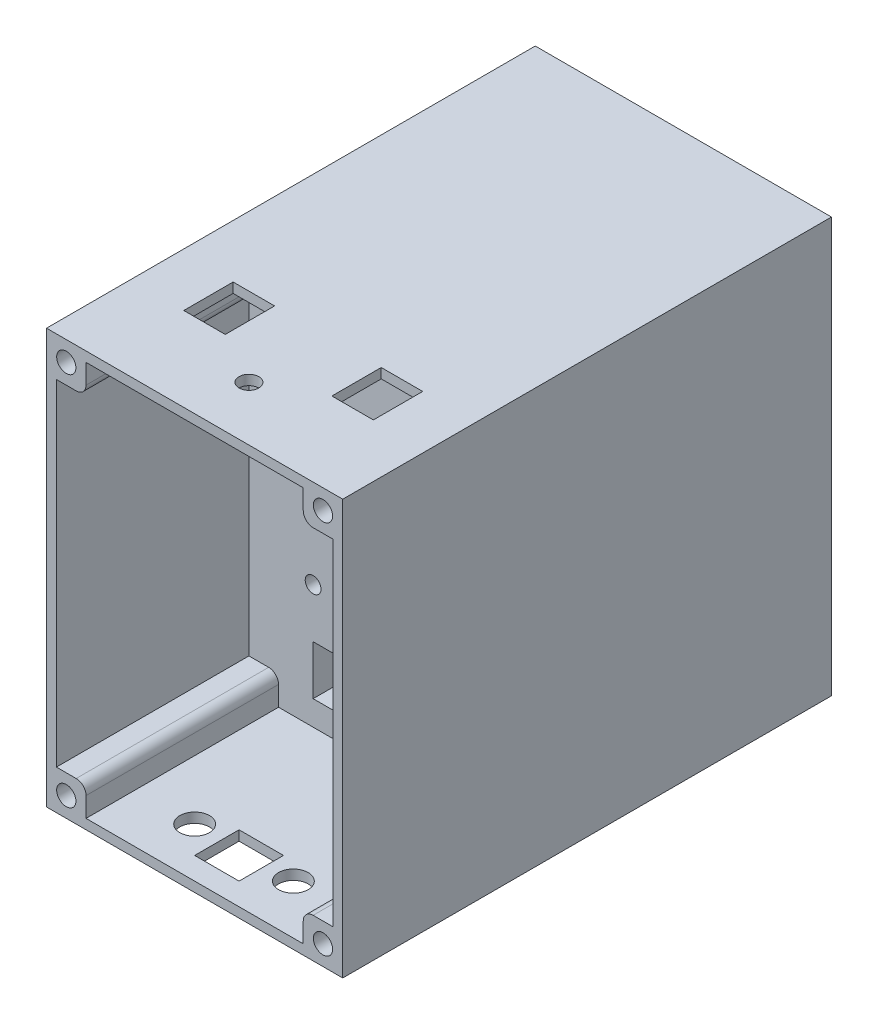
from build123d import *

# Parameters (mm, degrees)
SKETCH1_W                = 60
SKETCH1_H                = 84
BOSS_EXTRUDE2_DEPTH      = 82
BOSS_EXTRUDE2_DEPTH_BACK = 25
SKETCH2_W                = 56
SKETCH2_H                = 80
CUT_EXTRUDE1_DEPTH       = 108
BOSS_EXTRUDE6_DEPTH      = 107
SKETCH22_R               = 1.95
CUT_EXTRUDE6_DEPTH       = 25
CUT_EXTRUDE9_DEPTH       = 2
SKETCH28_W               = 8
SKETCH28_H               = 85.946450773
CUT_EXTRUDE11_DEPTH      = 60
BOSS_EXTRUDE9_DEPTH      = 84
SKETCH37_R               = 1.6
CUT_EXTRUDE15_DEPTH      = 4
CUT_EXTRUDE16_DEPTH      = 4
SKETCH41_R               = 2
CUT_EXTRUDE17_DEPTH      = 2
SKETCH42_R               = 11.5
CUT_EXTRUDE18_DEPTH      = 2.5
SKETCH43_R               = 5
CUT_EXTRUDE19_DEPTH      = 1.5
SKETCH44_R               = 3
CUT_EXTRUDE20_DEPTH      = 2


with BuildPart() as part:
    # Sketch1 → Boss-Extrude2 (new body, two sides)
    with BuildSketch(Plane.XY) as boss_extrude2_sk:
        with Locations((30, 42)):
            Rectangle(SKETCH1_W, SKETCH1_H)
    extrude(amount=BOSS_EXTRUDE2_DEPTH)
    extrude(boss_extrude2_sk.sketch, amount=-BOSS_EXTRUDE2_DEPTH_BACK)

    # Sketch2 → Cut-Extrude1 (cut, through all)
    with BuildSketch(Plane.XY.offset(82)):
        with Locations((30, 42)):
            Rectangle(SKETCH2_W, SKETCH2_H)
    extrude(amount=-CUT_EXTRUDE1_DEPTH, mode=Mode.SUBTRACT)

    # Sketch8 → Boss-Extrude6 (add)
    with BuildSketch(Plane(origin=(0, 0, -25), x_dir=(-1, 0, 0), z_dir=(0, 0, -1))):
        with BuildLine():
            Line((-58, 82), (-52, 82))
            Line((-52, 82), (-52, 78))
            ThreePointArc((-52, 78), (-52.585786438, 76.585786438), (-54, 76))
            Line((-54, 76), (-58, 76))
            Line((-58, 76), (-58, 82))
        make_face()
        with BuildLine():
            Line((-2, 2), (-8, 2))
            Line((-8, 2), (-8, 6))
            ThreePointArc((-8, 6), (-7.414213562, 7.414213562), (-6, 8))
            Line((-6, 8), (-2, 8))
            Line((-2, 8), (-2, 2))
        make_face()
        with BuildLine():
            Line((-2, 76), (-2, 82))
            Line((-2, 82), (-8, 82))
            Line((-8, 82), (-8, 78))
            ThreePointArc((-8, 78), (-7.414213562, 76.585786438), (-6, 76))
            Line((-6, 76), (-2, 76))
        make_face()
        with BuildLine():
            Line((-58, 8), (-58, 2))
            Line((-58, 2), (-52, 2))
            Line((-52, 2), (-52, 6))
            ThreePointArc((-52, 6), (-52.585786438, 7.414213562), (-54, 8))
            Line((-54, 8), (-58, 8))
        make_face()
    extrude(amount=-BOSS_EXTRUDE6_DEPTH)

    # Sketch22 → Cut-Extrude6 (cut)
    with BuildSketch(Plane(origin=(0, 0, -25), x_dir=(-1, 0, 0), z_dir=(0, 0, -1))):
        with Locations((-56, 80)):
            Circle(SKETCH22_R)
        with Locations((-4, 80)):
            Circle(SKETCH22_R)
        with Locations((-4, 4)):
            Circle(SKETCH22_R)
        with Locations((-56, 4)):
            Circle(SKETCH22_R)
    cut_extrude6 = extrude(amount=-CUT_EXTRUDE6_DEPTH, mode=Mode.SUBTRACT)

    # Sketch26 → Cut-Extrude9 (cut)
    with BuildSketch(Plane(origin=(0, 84, 0), x_dir=(1, 0, 0), z_dir=(0, 1, 0))):
        Polygon((15, -57), (10.8, -57), (10.8, -47), (19.2, -47), (19.2, -57), align=None)
        Polygon((40.8, -47), (40.8, -57), (45, -57), (49.2, -57), (49.2, -47), align=None)
    extrude(amount=-CUT_EXTRUDE9_DEPTH, mode=Mode.SUBTRACT)

    # Sketch28 → Cut-Extrude11 (cut)
    with BuildSketch(Plane.ZY):
        with Locations((78, 41.026774614)):
            Rectangle(SKETCH28_W, SKETCH28_H)
    extrude(amount=-CUT_EXTRUDE11_DEPTH, mode=Mode.SUBTRACT)

    # Sketch32 → Boss-Extrude9 (add)
    with BuildSketch(Plane(origin=(0, 84, 0), x_dir=(1, 0, 0), z_dir=(0, 1, 0))):
        Polygon((60, -33), (60, -35), (0, -35), (0, -33), (0, -31), (60, -31), align=None)
    extrude(amount=-BOSS_EXTRUDE9_DEPTH)

    # Sketch37 → Cut-Extrude15 (cut)
    with BuildSketch(Plane(origin=(0, 0, 31), x_dir=(-1, 0, 0), z_dir=(0, 0, -1))):
        with Locations((-15, 57)):
            Circle(SKETCH37_R)
        with Locations((-45, 57)):
            Circle(SKETCH37_R)
        with Locations((-45, 27)):
            Circle(SKETCH37_R)
        with Locations((-15, 27)):
            Circle(SKETCH37_R)
    extrude(amount=-CUT_EXTRUDE15_DEPTH, mode=Mode.SUBTRACT)

    # Sketch38 → Cut-Extrude16 (cut)
    with BuildSketch(Plane(origin=(0, 0, 31), x_dir=(-1, 0, 0), z_dir=(0, 0, -1))):
        Polygon((-30, 7), (-45, 7), (-45, 17), (-15, 17), (-15, 7), align=None)
    extrude(amount=-CUT_EXTRUDE16_DEPTH, mode=Mode.SUBTRACT)

    # Mirror1: Cut-Extrude6 across plane
    add(cut_extrude6.mirror(Plane(origin=(0, 0, 24.5), x_dir=(1, 0, 0), z_dir=(0, 0, -1))), mode=Mode.SUBTRACT)

    # Sketch41 → Cut-Extrude17 (cut)
    with BuildSketch(Plane(origin=(0, 84, 0), x_dir=(1, 0, 0), z_dir=(0, 1, 0))):
        with Locations((30, -63)):
            Circle(SKETCH41_R)
    extrude(amount=-CUT_EXTRUDE17_DEPTH, mode=Mode.SUBTRACT)

    # Sketch42 → Cut-Extrude18 (cut)
    with BuildSketch(Plane(origin=(0, 0, 31), x_dir=(-1, 0, 0), z_dir=(0, 0, -1))):
        with Locations((-30, 42)):
            Circle(SKETCH42_R)
    extrude(amount=-CUT_EXTRUDE18_DEPTH, mode=Mode.SUBTRACT)

    # Sketch43 → Cut-Extrude19 (cut)
    with BuildSketch(Plane(origin=(0, 0, 33.5), x_dir=(-1, 0, 0), z_dir=(0, 0, -1))):
        with Locations((-30, 42)):
            Circle(SKETCH43_R)
    extrude(amount=-CUT_EXTRUDE19_DEPTH, mode=Mode.SUBTRACT)

    # Sketch44 → Cut-Extrude20 (cut)
    with BuildSketch(Plane.XZ):
        with Locations((20, 64)):
            Circle(SKETCH44_R)
        with Locations((40, 64)):
            Circle(SKETCH44_R)
        Polygon((30, 69.5), (25.5, 69.5), (25.5, 60.5), (34.5, 60.5), (34.5, 69.5), align=None)
    extrude(amount=-CUT_EXTRUDE20_DEPTH, mode=Mode.SUBTRACT)


solid = part.part
